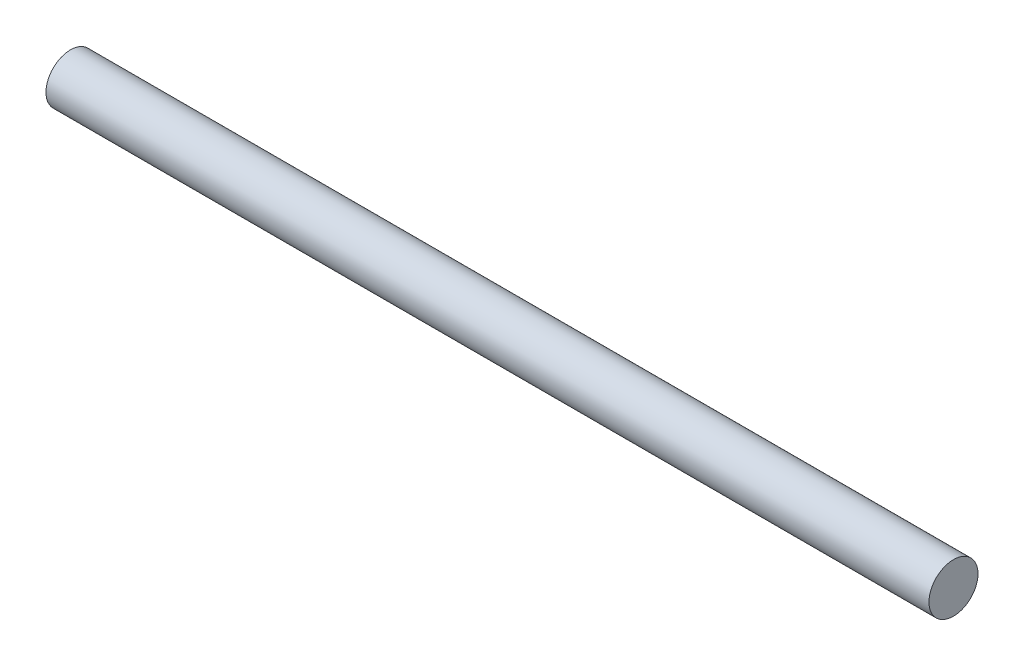
from build123d import *

# Parameters (mm, degrees)
SKETCH2_R           = 6.35
BOSS_EXTRUDE1_DEPTH = 228.6


with BuildPart() as part:
    # Sketch2 → Boss-Extrude1 (new body)
    with BuildSketch(Plane(origin=(0, 0, 0), x_dir=(0, 0, -1), z_dir=(1, 0, 0))):
        Circle(SKETCH2_R)
    extrude(amount=BOSS_EXTRUDE1_DEPTH)


solid = part.part
